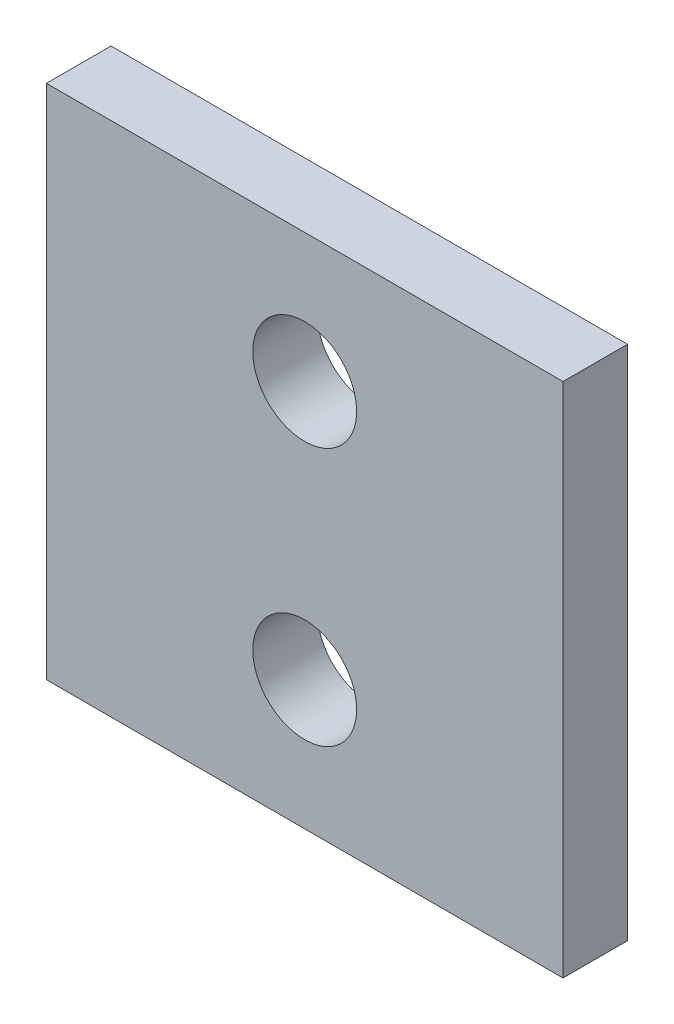
from build123d import *

# Parameters (mm, degrees)
SKETCH1_W           = 25.4
SKETCH1_H           = 25.4
BOSS_EXTRUDE1_DEPTH = 3.175
CUT_EXTRUDE1_REACH  = 5.175
SKETCH2_R           = 2.5527


with BuildPart() as part:
    # Sketch1 → Boss-Extrude1 (new body)
    with BuildSketch(Plane.XY):
        with Locations((12.7, 12.7)):
            Rectangle(SKETCH1_W, SKETCH1_H)
    extrude(amount=BOSS_EXTRUDE1_DEPTH)

    # Sketch2 → Cut-Extrude1 (cut, up to next)
    with BuildSketch(Plane(origin=(0, 0, 0), x_dir=(-1, 0, 0), z_dir=(0, 0, -1)), mode=Mode.PRIVATE) as cut_extrude1_sk1:
        with Locations((-12.7, 6.35)):
            Circle(SKETCH2_R)
    cut_extrude1_tool1 = extrude(cut_extrude1_sk1.sketch, amount=-CUT_EXTRUDE1_REACH, mode=Mode.PRIVATE) & part.part
    add(cut_extrude1_tool1.solids().sort_by_distance((12.7, 6.35, 0))[0], mode=Mode.SUBTRACT)
    # Sketch2 → Cut-Extrude1 (cut, up to next)
    with BuildSketch(Plane(origin=(0, 0, 0), x_dir=(-1, 0, 0), z_dir=(0, 0, -1)), mode=Mode.PRIVATE) as cut_extrude1_sk2:
        with Locations((-12.7, 19.05)):
            Circle(SKETCH2_R)
    cut_extrude1_tool2 = extrude(cut_extrude1_sk2.sketch, amount=-CUT_EXTRUDE1_REACH, mode=Mode.PRIVATE) & part.part
    add(cut_extrude1_tool2.solids().sort_by_distance((12.7, 19.05, 0))[0], mode=Mode.SUBTRACT)


solid = part.part
